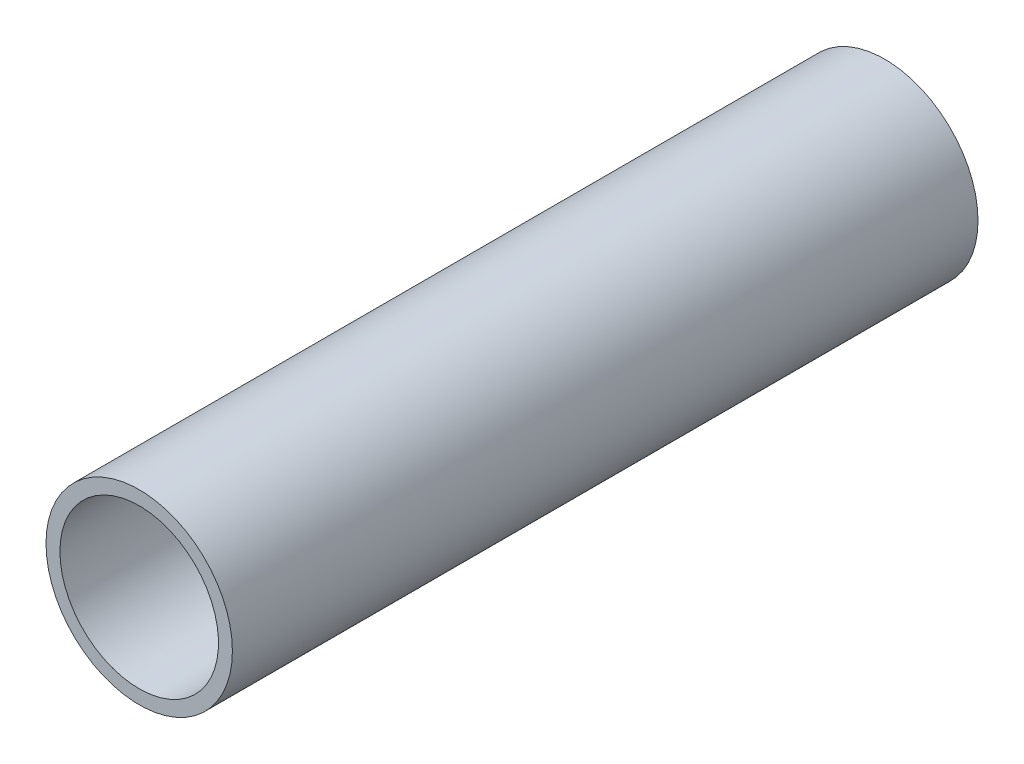
from build123d import *

# Parameters (mm, degrees)
SKETCH3_R           = 4.7625
SKETCH3_R_2         = 4.0513
BOSS_EXTRUDE1_DEPTH = 19.05


with BuildPart() as part:
    # Sketch3 → Boss-Extrude1 (new, symmetric)
    with BuildSketch(Plane.XY):
        with Locations(Location((0, 0, 0), (0, 0, 180))):
            Circle(SKETCH3_R)
        with Locations(Location((0, 0, 0), (0, 0, 180))):
            Circle(SKETCH3_R_2, mode=Mode.SUBTRACT)
    extrude(amount=BOSS_EXTRUDE1_DEPTH, both=True)


solid = part.part
